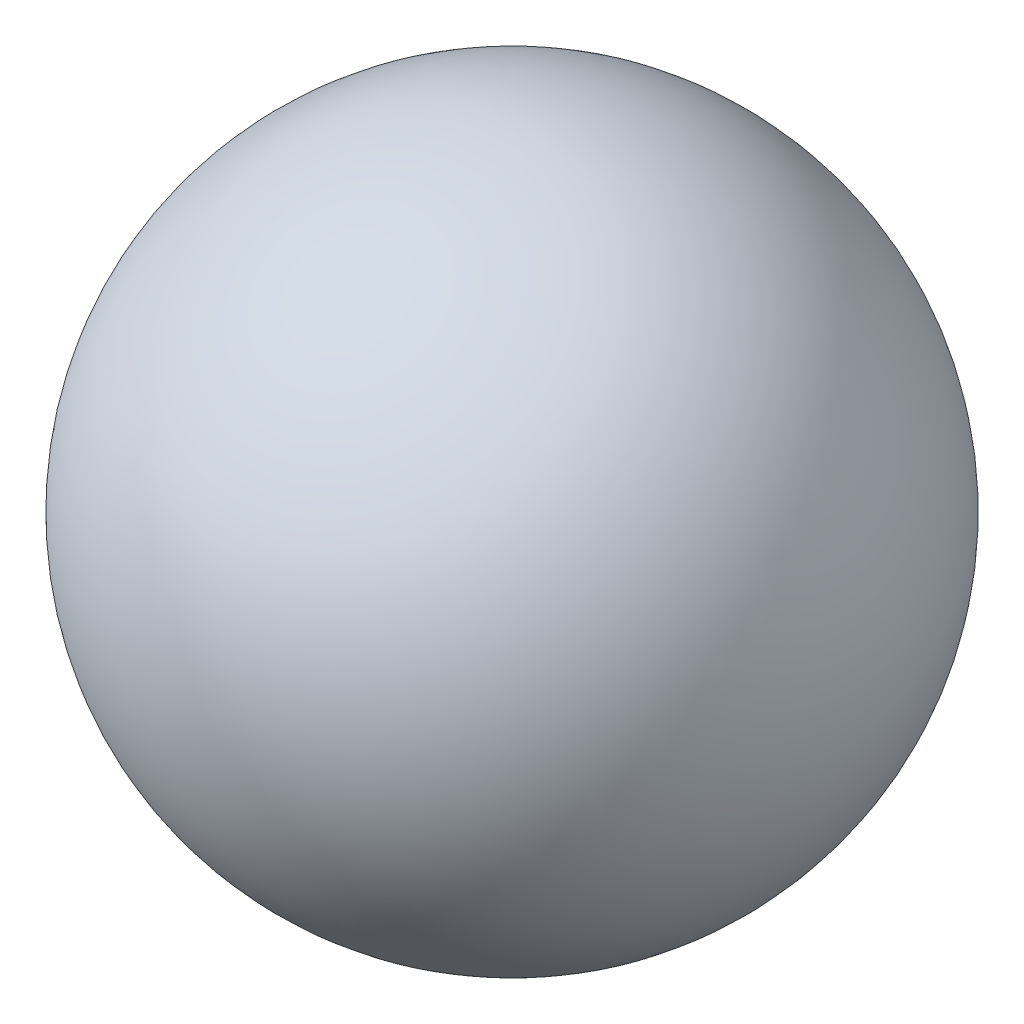
from build123d import *


with BuildPart() as part:
    # Sketch1 → Revolve1 (revolve)
    with BuildSketch(Plane.XY):
        with BuildLine():
            Line((0, 87.583918356), (0, -87.583918356))
            ThreePointArc((0, -87.583918356), (-87.583918356, 0), (0, 87.583918356))
        make_face()
    revolve(axis=Axis((0, 87.583918356, 0), (0, -1, 0)))


solid = part.part
